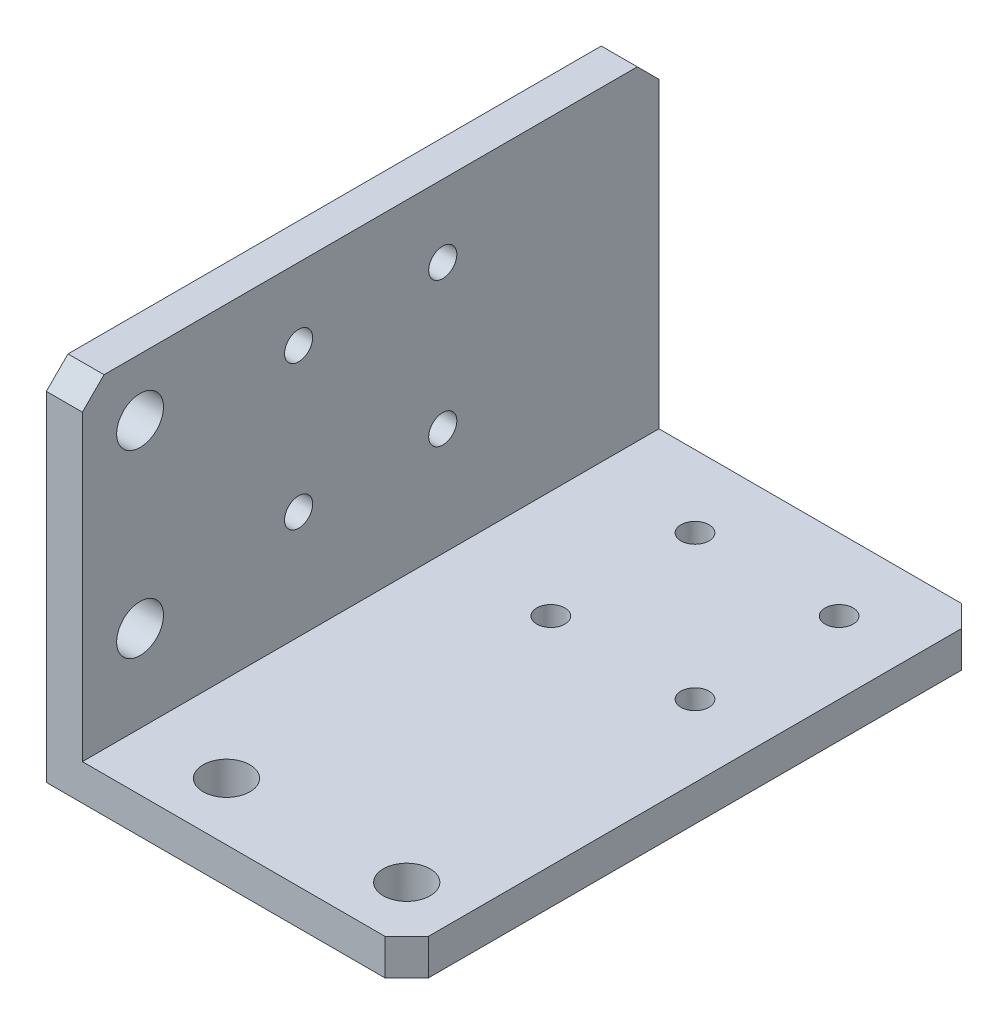
from build123d import *

# Parameters (mm, degrees)
ESTRUSIONE_ESTRUSIONE1_DEPTH = 80
FORO_6_5_6_5_1_D             = 6.5
FORO_6_5_6_5_2_D             = 6.5
FORO_6_5_6_5_2_DEPTH         = 5
FORO_6_5_6_5_2_TIP           = 1.952797012
SMUSSO1_SIZE                 = 3
M3_5_CLEARANCE_HOLE1_D       = 3.9
M3_5_CLEARANCE_HOLE2_D       = 3.9


with BuildPart() as part:
    # Schizzo1 → Estrusione-Estrusione1 (new body)
    with BuildSketch(Plane.XY):
        Polygon((0, 0), (0, 50), (5, 50), (5, 5), (50, 5), (50, 0), align=None)
    extrude(amount=ESTRUSIONE_ESTRUSIONE1_DEPTH)

    # Foro Ø6.5 (6.5)-1 (through all)
    with Locations(Plane(origin=(0, 0, 0), x_dir=(-1, 0, 0), z_dir=(0, -1, 0))):
        with Locations((-17, -72), (-42, -72)):
            Hole(FORO_6_5_6_5_1_D / 2)

    # Foro Ø6.5 (6.5)-2
    with Locations(Plane.ZY):
        with Locations((72, 42), (72, 17)):
            Hole(FORO_6_5_6_5_2_D / 2, depth=FORO_6_5_6_5_2_DEPTH)
            with Locations((0, 0, -(FORO_6_5_6_5_2_DEPTH + FORO_6_5_6_5_2_TIP / 2))):  # 118° drill point
                Cone(0, FORO_6_5_6_5_2_D / 2, FORO_6_5_6_5_2_TIP, mode=Mode.SUBTRACT)

    # Smusso1
    smusso1_edges = [part.edges().sort_by_distance(p)[0] for p in [
        (2.5, 50, 80),
        (2.5, 50, 0),
        (50, 2.5, 80),
        (50, 2.5, 0),
    ]]
    chamfer(smusso1_edges, length=SMUSSO1_SIZE)

    # M3.5 Clearance Hole1 (through all)
    with Locations(Plane(origin=(20, 0, 30), x_dir=(-1, 0, 0), z_dir=(0, -1, 0))):
        with Locations((0, 0), (-20, 0), (-20, 20), (0, 20)):
            Hole(M3_5_CLEARANCE_HOLE1_D / 2)

    # M3.5 Clearance Hole2 (through all)
    with Locations(Plane(origin=(0, 40, 30), x_dir=(0, 0, -1), z_dir=(-1, 0, 0))):
        with Locations((0, 0), (-20, 0), (-20, 20), (0, 20)):
            Hole(M3_5_CLEARANCE_HOLE2_D / 2)


solid = part.part
